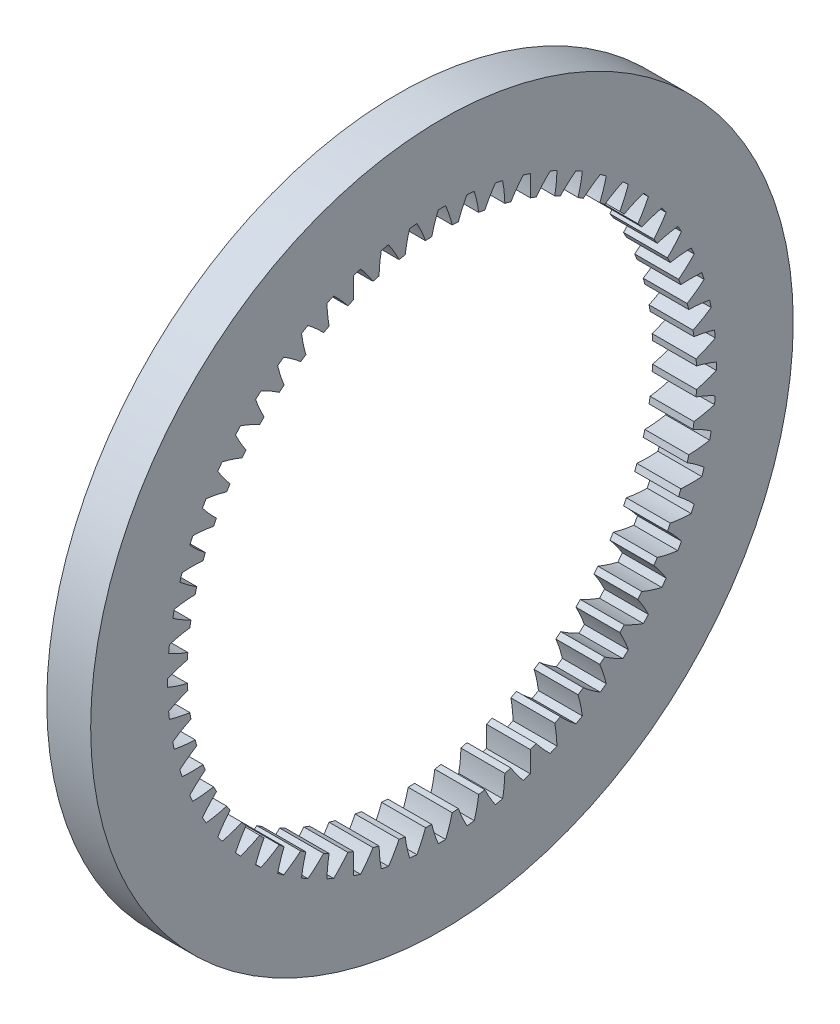
from build123d import *

# Parameters (mm, degrees)
BASPROSKE_W     = 5
BASPROSKE_H     = 11
TOOTHCUT_DEPTH  = 57.789083458
TEETHCUTS_COUNT = 60
TEETHCUTS_ANGLE = 354


with BuildPart() as part:
    # BasProSke → Base-Revolve (revolve)
    with BuildSketch(Plane(origin=(0, 0, 0), x_dir=(1, 0, 0), z_dir=(0, 1, 0))):
        with Locations((2.5, 34.5)):
            Rectangle(BASPROSKE_W, BASPROSKE_H)
    revolve(axis=Axis((-10, 0, 0), (1, 0, 0)))

    # TooCutSke → ToothCut (cut, through all)
    with BuildSketch(Plane(origin=(0, 0, 0), x_dir=(0, 0, -1), z_dir=(1, 0, 0))):
        with BuildLine():
            ThreePointArc((1.166899632, 28.951093078), (0.839396859, 30.114715411), (0.419258803, 31.248187516))
            ThreePointArc((0.419258803, 31.248187516), (0, 31.251), (-0.419258803, 31.248187516))
            ThreePointArc((-0.419258803, 31.248187516), (-0.839396859, 30.114715411), (-1.166899632, 28.951093078))
            ThreePointArc((-1.166899632, 28.951093078), (0, 28.9746), (1.166899632, 28.951093078))
        make_face()
    toothcut = extrude(amount=TOOTHCUT_DEPTH, mode=Mode.SUBTRACT)

    # TeethCuts: ToothCut ×60 about axis
    teethcuts_axis = Axis((-10, 0, 0), (1, 0, 0))
    for i in range(1, TEETHCUTS_COUNT):
        add(toothcut.rotate(teethcuts_axis, i * TEETHCUTS_ANGLE / (TEETHCUTS_COUNT - 1)), mode=Mode.SUBTRACT)


solid = part.part
